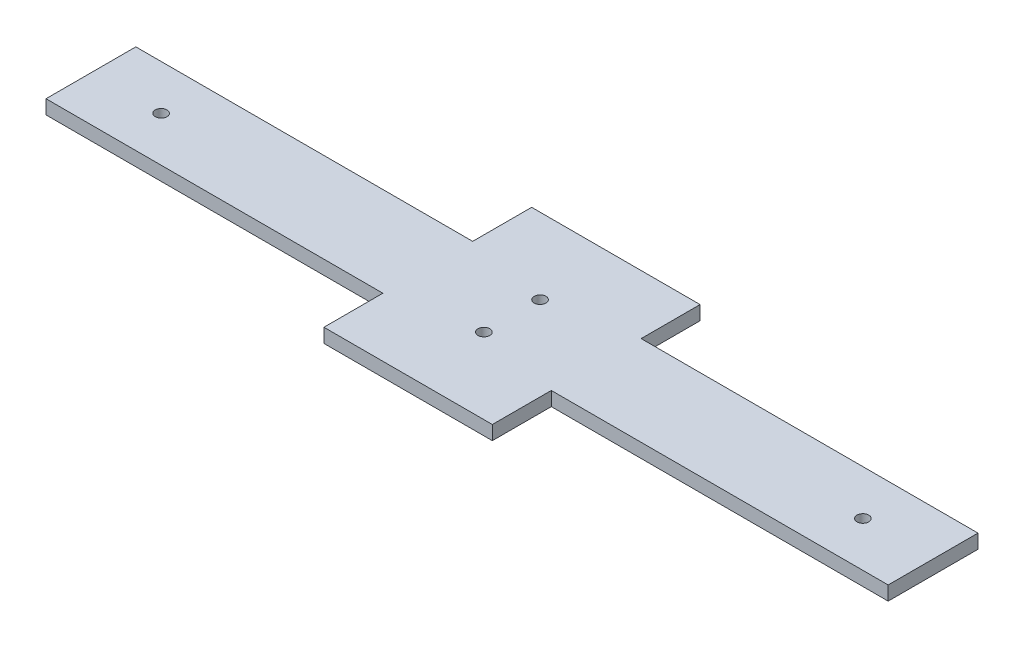
from build123d import *

# Parameters (mm, degrees)
EXTRUDE_1_DEPTH     = 5
SKETCH_2_R          = 2.1
CUT_EXTRUDE_1_DEPTH = 6
FILLET_1_R          = 5
SKETCH_3_R          = 2.5
CUT_EXTRUDE_2_DEPTH = 6
SKETCH_4_R          = 2.1
CUT_EXTRUDE_3_DEPTH = 6
SKETCH_5_OUTSIDE_W  = 532.64
SKETCH_5_OUTSIDE_H  = 472.64
CUT_EXTRUDE_4_DEPTH = 6


with BuildPart() as part:
    # 草图1 → 凸台-拉伸1 (new body)
    with BuildSketch(Plane(origin=(0, 0, 0), x_dir=(1, 0, 0), z_dir=(0, 1, 0))):
        Polygon((-180, 180), (-180, 103), (-80, 103), (-80, 180), (80, 180), (80, 103), (180, 103), (180, 180), (210, 180), (210, -180), (180, -180), (180, -103), (80, -103), (80, -180), (-80, -180), (-80, -103), (-180, -103), (-180, -180), (-210, -180), (-210, 180), align=None)
    extrude(amount=EXTRUDE_1_DEPTH)

    # 草图2 → 切除-拉伸1 (cut, through all)
    with BuildSketch(Plane(origin=(0, 5, 0), x_dir=(1, 0, 0), z_dir=(0, 1, 0))):
        with Locations((115, -88.5)):
            Circle(SKETCH_2_R)
        with Locations((145, -88.5)):
            Circle(SKETCH_2_R)
        with Locations((130, -95.5)):
            Circle(SKETCH_2_R)
        with Locations((130, 95.5)):
            Circle(SKETCH_2_R)
        with Locations((145, 88.5)):
            Circle(SKETCH_2_R)
        with Locations((115, 88.5)):
            Circle(SKETCH_2_R)
        with Locations((-115, 88.5)):
            Circle(SKETCH_2_R)
        with Locations((-145, 88.5)):
            Circle(SKETCH_2_R)
        with Locations((-130, 95.5)):
            Circle(SKETCH_2_R)
        with Locations((-130, -95.5)):
            Circle(SKETCH_2_R)
        with Locations((-145, -88.5)):
            Circle(SKETCH_2_R)
        with Locations((-115, -88.5)):
            Circle(SKETCH_2_R)
    extrude(amount=-CUT_EXTRUDE_1_DEPTH, mode=Mode.SUBTRACT)

    # 圆角1
    fillet_1_edges = [part.edges().sort_by_distance(p)[0] for p in [
        (180, 2.5, 180),
        (80, 2.5, 180),
        (-80, 2.5, 180),
        (-180, 2.5, 180),
        (-180, 2.5, -180),
        (-80, 2.5, -180),
        (80, 2.5, -180),
        (180, 2.5, -180),
    ]]
    fillet(fillet_1_edges, radius=FILLET_1_R)

    # 草图3 → 切除-拉伸2 (cut, through all)
    with BuildSketch(Plane.XZ):
        with Locations((84.75, 31.75)):
            Circle(SKETCH_3_R)
        with Locations((84.75, -31.75)):
            Circle(SKETCH_3_R)
        with Locations((171.25, 31.75)):
            Circle(SKETCH_3_R)
        with Locations((171.25, -31.75)):
            Circle(SKETCH_3_R)
        with Locations((-171.25, -31.75)):
            Circle(SKETCH_3_R)
        with Locations((-171.25, 31.75)):
            Circle(SKETCH_3_R)
        with Locations((-84.75, -31.75)):
            Circle(SKETCH_3_R)
        with Locations((-84.75, 31.75)):
            Circle(SKETCH_3_R)
    extrude(amount=-CUT_EXTRUDE_2_DEPTH, mode=Mode.SUBTRACT)

    # 草图4 → 切除-拉伸3 (cut, through all)
    with BuildSketch(Plane.XZ):
        with Locations((-125, 0)):
            Circle(SKETCH_4_R)
        with Locations((125, 0)):
            Circle(SKETCH_4_R)
        with Locations((0, 10)):
            Circle(SKETCH_4_R)
        with Locations((0, -10)):
            Circle(SKETCH_4_R)
    extrude(amount=-CUT_EXTRUDE_3_DEPTH, mode=Mode.SUBTRACT)

    # 草图5 outside → 切除-拉伸4 (cut, through all)
    with BuildSketch(Plane.XZ):
        Rectangle(SKETCH_5_OUTSIDE_W, SKETCH_5_OUTSIDE_H)
        Polygon((-150, 16), (-150, -16), (-30, -16), (-30, -37), (30, -37), (30, -16), (150, -16), (150, 16), (30, 16), (30, 37), (-30, 37), (-30, 16), align=None, mode=Mode.SUBTRACT)
    extrude(amount=-CUT_EXTRUDE_4_DEPTH, mode=Mode.SUBTRACT)


solid = part.part
